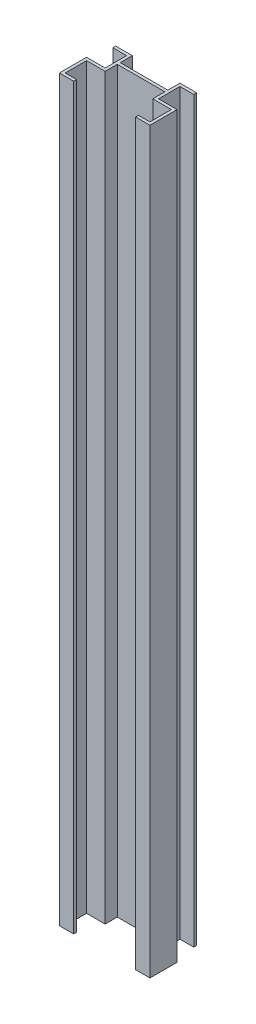
from build123d import *

# Parameters (mm, degrees)
SKETCH1_W                      = 45
SKETCH1_H                      = 2350
BOSS_EXTRUDE1_DEPTH            = 31.5
SKETCH2_W                      = 6
SKETCH2_H                      = 2350
BOSS_EXTRUDE2_DEPTH            = 145
SKETCH3_W                      = 45
SKETCH3_H                      = 2350
BOSS_EXTRUDE3_DEPTH            = 76.5
SKETCH4_W                      = 6
SKETCH4_H                      = 2350
BOSS_EXTRUDE4_DEPTH            = 51
SKETCH5_W                      = 6
SKETCH5_H                      = 2350
BOSS_EXTRUDE5_DEPTH            = 24
SKETCH6_W                      = 15
SKETCH6_H                      = 2350
CUT_EXTRUDE1_DEPTH             = 6
SKETCH7_W                      = 39
SKETCH7_H                      = 2350
CUT_EXTRUDE2_DEPTH             = 45
SKETCH8_W                      = 100
SKETCH8_H                      = 6
CUT_EXTRUDE3_DEPTH             = 100
SKETCH9_W                      = 45
SKETCH9_H                      = 2350
BOSS_EXTRUDE6_DEPTH            = 25.5
SKETCH10_W                     = 39
SKETCH10_H                     = 51
CUT_EXTRUDE4_DEPTH             = 2351
SKETCH11_W                     = 6
SKETCH11_H                     = 2350
BOSS_EXTRUDE7_DEPTH            = 29
SKETCH12_W                     = 45
SKETCH12_H                     = 2350
BOSS_EXTRUDE8_DEPTH            = 25.5
SKETCH13_W                     = 39
SKETCH13_H                     = 51
CUT_EXTRUDE5_DEPTH             = 2351
SKETCH14_W                     = 6
SKETCH14_H                     = 2350
BOSS_EXTRUDE9_DEPTH            = 29
F_10_0_10_DIAMETER_HOLE1_D     = 10
F_10_0_10_DIAMETER_HOLE1_DEPTH = 6
F_10_0_10_DIAMETER_HOLE2_D     = 10
F_10_0_10_DIAMETER_HOLE2_DEPTH = 45
SKETCH24_W                     = 287.862467109
SKETCH24_H                     = 163.242221956
CUT_EXTRUDE8_DEPTH             = 800


with BuildPart() as part:
    # Sketch1 → Boss-Extrude1 (new body)
    with BuildSketch(Plane(origin=(0, 0, -76.5), x_dir=(-1, 0, 0), z_dir=(0, 0, -1))):
        with Locations((-72.5, 1175)):
            Rectangle(SKETCH1_W, SKETCH1_H)
    extrude(amount=-BOSS_EXTRUDE1_DEPTH)

    # Sketch2 → Boss-Extrude2 (add)
    with BuildSketch(Plane.ZY.offset(-50)):
        with Locations((-73.5, 1175)):
            Rectangle(SKETCH2_W, SKETCH2_H)
    extrude(amount=BOSS_EXTRUDE2_DEPTH)

    # Sketch3 → Boss-Extrude3 (add)
    with BuildSketch(Plane.XY.offset(-70.5)):
        with Locations((-72.5, 1175)):
            Rectangle(SKETCH3_W, SKETCH3_H)
    extrude(amount=BOSS_EXTRUDE3_DEPTH)

    # Sketch4 → Boss-Extrude4 (add)
    with BuildSketch(Plane.XY.offset(-45)):
        with Locations((92, 1175)):
            Rectangle(SKETCH4_W, SKETCH4_H)
    extrude(amount=BOSS_EXTRUDE4_DEPTH)

    # Sketch5 → Boss-Extrude5 (add)
    with BuildSketch(Plane.ZY.offset(-89)):
        with Locations((3, 1175)):
            Rectangle(SKETCH5_W, SKETCH5_H)
    extrude(amount=BOSS_EXTRUDE5_DEPTH)

    # Sketch6 → Cut-Extrude1 (cut)
    with BuildSketch(Plane.XY.offset(6)):
        with Locations((-57.5, 1175)):
            Rectangle(SKETCH6_W, SKETCH6_H)
    extrude(amount=-CUT_EXTRUDE1_DEPTH, mode=Mode.SUBTRACT)

    # Sketch7 → Cut-Extrude2 (cut)
    with BuildSketch(Plane.XY):
        with Locations((-69.5, 1175)):
            Rectangle(SKETCH7_W, SKETCH7_H)
    extrude(amount=-CUT_EXTRUDE2_DEPTH, mode=Mode.SUBTRACT)

    # Sketch8 → Cut-Extrude3 (cut)
    with BuildSketch(Plane(origin=(0, 2350, 0), x_dir=(-1, 0, 0), z_dir=(0, 1, 0))):
        with Locations((0, -73.5)):
            Rectangle(SKETCH8_W, SKETCH8_H)
    extrude(amount=-CUT_EXTRUDE3_DEPTH, mode=Mode.SUBTRACT)

    # Sketch9 → Boss-Extrude6 (add)
    with BuildSketch(Plane(origin=(0, 0, -76.5), x_dir=(-1, 0, 0), z_dir=(0, 0, -1))):
        with Locations((-72.5, 1175)):
            Rectangle(SKETCH9_W, SKETCH9_H)
    extrude(amount=BOSS_EXTRUDE6_DEPTH)

    # Sketch10 → Cut-Extrude4 (cut, through all)
    with BuildSketch(Plane.XZ):
        with Locations((75.5, -76.5)):
            Rectangle(SKETCH10_W, SKETCH10_H)
    extrude(amount=-CUT_EXTRUDE4_DEPTH, mode=Mode.SUBTRACT)

    # Sketch11 → Boss-Extrude7 (add)
    with BuildSketch(Plane(origin=(56, 0, 0), x_dir=(0, 0, -1), z_dir=(1, 0, 0))):
        with Locations((99, 1175)):
            Rectangle(SKETCH11_W, SKETCH11_H)
    extrude(amount=BOSS_EXTRUDE7_DEPTH)

    # Sketch12 → Boss-Extrude8 (add)
    with BuildSketch(Plane(origin=(0, 0, -76.5), x_dir=(-1, 0, 0), z_dir=(0, 0, -1))):
        with Locations((72.5, 1175)):
            Rectangle(SKETCH12_W, SKETCH12_H)
    extrude(amount=BOSS_EXTRUDE8_DEPTH)

    # Sketch13 → Cut-Extrude5 (cut, through all)
    with BuildSketch(Plane(origin=(0, 2350, 0), x_dir=(-1, 0, 0), z_dir=(0, 1, 0))):
        with Locations((75.5, -76.5)):
            Rectangle(SKETCH13_W, SKETCH13_H)
    extrude(amount=-CUT_EXTRUDE5_DEPTH, mode=Mode.SUBTRACT)

    # Sketch14 → Boss-Extrude9 (add)
    with BuildSketch(Plane.ZY.offset(56)):
        with Locations((-99, 1175)):
            Rectangle(SKETCH14_W, SKETCH14_H)
    extrude(amount=BOSS_EXTRUDE9_DEPTH)

    # Ø10.0 (10) Diameter Hole1
    with Locations(Plane.ZY.offset(56)):
        with Locations((-73.5, 2330)):
            Hole(F_10_0_10_DIAMETER_HOLE1_D / 2, depth=F_10_0_10_DIAMETER_HOLE1_DEPTH)

    # Ø10.0 (10) Diameter Hole2
    with Locations(Plane.ZY.offset(-50)):
        with Locations((-73.5, 2330)):
            Hole(F_10_0_10_DIAMETER_HOLE2_D / 2, depth=F_10_0_10_DIAMETER_HOLE2_DEPTH)

    # Sketch24 → Cut-Extrude8 (cut)
    with BuildSketch(Plane(origin=(0, 2350, 0), x_dir=(1, 0, 0), z_dir=(0, 1, 0))):
        with Locations((3.257138833, 40.584576945)):
            Rectangle(SKETCH24_W, SKETCH24_H)
    extrude(amount=-CUT_EXTRUDE8_DEPTH, mode=Mode.SUBTRACT)


solid = part.part
